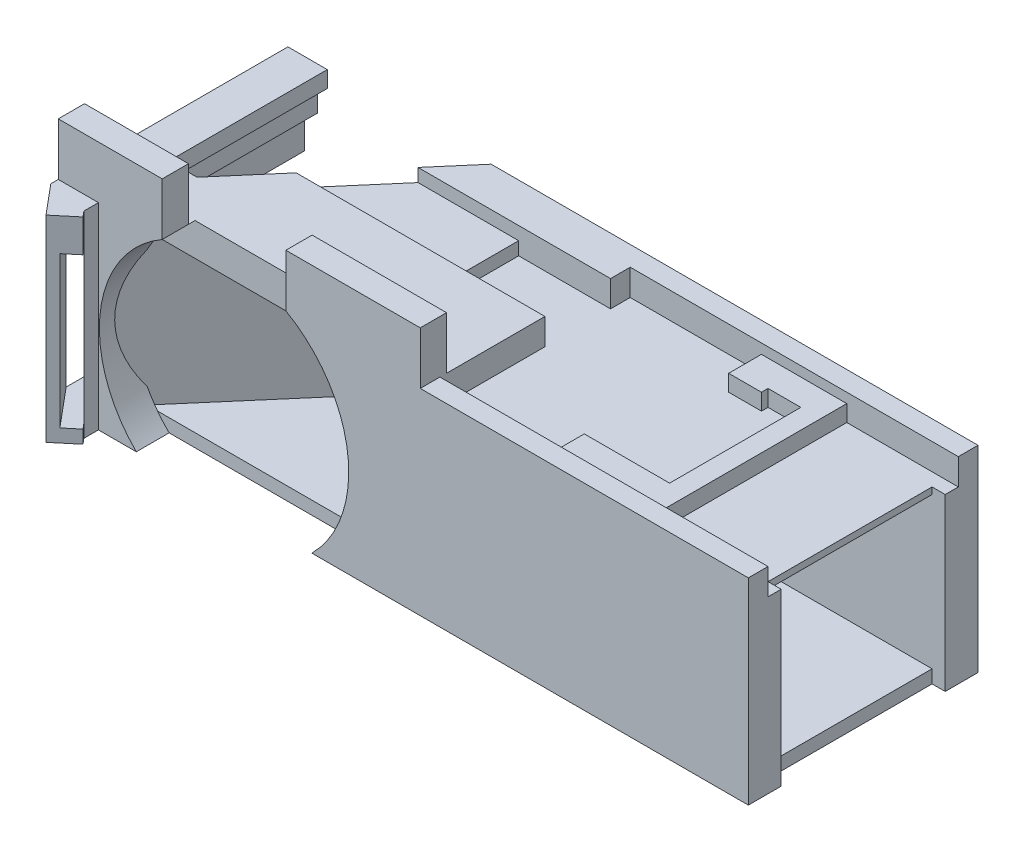
from build123d import *

# Parameters (mm, degrees)
BOSS_EXTRUDE3_DEPTH       = 30
SKETCH6_W                 = 25
SKETCH6_H                 = 23
CUT_EXTRUDE1_DEPTH        = 86
SKETCH7_W                 = 25
SKETCH7_H                 = 5
CUT_EXTRUDE2_DEPTH        = 7.5
SKETCH8_W                 = 25
SKETCH8_H                 = 2
CUT_EXTRUDE3_DEPTH        = 1
SKETCH9_R                 = 19
CUT_EXTRUDE4_DEPTH        = 5
BOSS_EXTRUDE4_DEPTH       = 30
SKETCH10_W                = 1.856561782
SKETCH10_H                = 30
BOSS_EXTRUDE5_DEPTH       = 3
BOSS_EXTRUDE6_DEPTH       = 30
SKETCH11_W                = 2.5
SKETCH11_H                = 23
CUT_EXTRUDE5_DEPTH        = 34.579503854
SKETCH12_W                = 29.135235428
SKETCH12_H                = 25
CUT_EXTRUDE6_DEPTH        = 3.5
SKETCH13_W                = 19.135235428
SKETCH13_H                = 5
CUT_EXTRUDE7_DEPTH        = 3.5
SKETCH14_W                = 29.135235428
SKETCH14_H                = 4
BOSS_EXTRUDE7_DEPTH       = 2
SKETCH16_W                = 29.135235428
SKETCH16_H                = 1.5
BOSS_EXTRUDE8_DEPTH       = 2
SKETCH17_W                = 2.551467674
SKETCH17_H                = 30
BOSS_EXTRUDE9_DEPTH       = 5
BOSS_EXTRUDE10_REACH      = 85.266
SKETCH18_W                = 29.135235428
SKETCH18_H                = 2.5
SKETCH19_W                = 2.48850009
SKETCH19_H                = 23
BOSS_EXTRUDE11_DEPTH      = 2
CUT_EXTRUDE8_START        = -2.4885
SKETCH20_W                = 2
SKETCH20_H                = 23
CUT_EXTRUDE8_DEPTH        = 21.736568
BOSS_EXTRUDE12_REACH      = 82.714
SKETCH21_W                = 2.023287715
SKETCH21_H                = 27.5
SKETCH22_W                = 35
SKETCH22_H                = 30
BOSS_EXTRUDE13_DEPTH      = 15.9
BOSS_EXTRUDE13_DEPTH_BACK = 7.5
SKETCH23_W                = 25
SKETCH23_H                = 23
CUT_EXTRUDE9_DEPTH        = 24.4
SKETCH24_W                = 25
SKETCH24_H                = 5
CUT_EXTRUDE10_DEPTH       = 2
SKETCH25_W                = 50
SKETCH25_H                = 29
CUT_EXTRUDE11_DEPTH       = 4
SKETCH26_W                = 3
SKETCH26_H                = 29
BOSS_EXTRUDE14_DEPTH      = 2.5
SKETCH27_W                = 5
SKETCH27_H                = 5
BOSS_EXTRUDE15_DEPTH      = 2.5
BOSS_EXTRUDE16_REACH      = 27
SKETCH28_W                = 4
SKETCH28_H                = 2.5
SKETCH29_W                = 13
SKETCH29_H                = 5
BOSS_EXTRUDE17_DEPTH      = 2.5
SKETCH30_W                = 10
SKETCH30_H                = 4
CUT_EXTRUDE12_DEPTH       = 14
CUT_EXTRUDE13_REACH       = 43.166
SKETCH31_W                = 10
SKETCH31_H                = 2
SKETCH32_W                = 2
SKETCH32_H                = 25
CUT_EXTRUDE14_DEPTH       = 27
SKETCH33_W                = 20.479278159
SKETCH33_H                = 4
BOSS_EXTRUDE18_DEPTH      = 8
SKETCH34_W                = 15.845031547
SKETCH34_H                = 4
BOSS_EXTRUDE19_DEPTH      = 8


with BuildPart() as part:
    # Sketch2 → Boss-Extrude3 (new body)
    with BuildSketch(Plane(origin=(0, 0, 0), x_dir=(1, 0, 0), z_dir=(0, 1, 0))):
        Polygon((-105.912162162, 13.018018018), (-20.912162162, 13.018018018), (-20.912162162, 48.018018018), (-75.912162162, 48.018018018), align=None)
    extrude(amount=BOSS_EXTRUDE3_DEPTH)

    # Sketch6 → Cut-Extrude1 (cut, through all)
    with BuildSketch(Plane(origin=(-20.912162162, 0, 0), x_dir=(0, 0, -1), z_dir=(1, 0, 0))):
        with Locations((30.518018018, 13.5)):
            Rectangle(SKETCH6_W, SKETCH6_H)
    extrude(amount=-CUT_EXTRUDE1_DEPTH, mode=Mode.SUBTRACT)

    # Sketch7 → Cut-Extrude2 (cut)
    with BuildSketch(Plane(origin=(-20.912162162, 0, 0), x_dir=(0, 0, -1), z_dir=(1, 0, 0))):
        with Locations((30.518018018, 27.5)):
            Rectangle(SKETCH7_W, SKETCH7_H)
    extrude(amount=-CUT_EXTRUDE2_DEPTH, mode=Mode.SUBTRACT)

    # Sketch8 → Cut-Extrude3 (cut)
    with BuildSketch(Plane(origin=(-20.912162162, 0, 0), x_dir=(0, 0, -1), z_dir=(1, 0, 0))):
        with Locations((30.518018018, 1)):
            Rectangle(SKETCH8_W, SKETCH8_H)
    extrude(amount=-CUT_EXTRUDE3_DEPTH, mode=Mode.SUBTRACT)

    # Sketch9 → Cut-Extrude4 (cut)
    with BuildSketch(Plane.XY.offset(-13.018018018)):
        with Locations((-84.912162162, 13.5)):
            Circle(SKETCH9_R)
    extrude(amount=-CUT_EXTRUDE4_DEPTH, mode=Mode.SUBTRACT)

    # Sketch3 → Boss-Extrude4 (add)
    with BuildSketch(Plane(origin=(0, 0, 0), x_dir=(1, 0, 0), z_dir=(0, 1, 0))):
        Polygon((-106.412808957, 7.383361614), (-110.17791555, 11.88278259), (-79.204856611, 48.018018018), (-75.912162162, 48.018018018), (-105.912162162, 13.018018018), (-103.345157358, 9.950366419), align=None)
    extrude(amount=BOSS_EXTRUDE4_DEPTH)

    # Sketch10 → Boss-Extrude5 (add)
    with BuildSketch(Plane.XY.offset(-13.018018018)):
        with Locations((-104.983881271, 15)):
            Rectangle(SKETCH10_W, SKETCH10_H)
    extrude(amount=BOSS_EXTRUDE5_DEPTH)

    # Sketch4 → Boss-Extrude6 (add)
    with BuildSketch(Plane(origin=(0, 0, 0), x_dir=(1, 0, 0), z_dir=(0, 1, 0))):
        Polygon((-110.17791555, 11.88278259), (-110.17791555, 48.018018018), (-104.17791555, 48.018018018), (-104.17791555, 18.88278259), align=None)
    extrude(amount=BOSS_EXTRUDE6_DEPTH)

    # Sketch11 → Cut-Extrude5 (cut, through all)
    with BuildSketch(Plane(origin=(-47.459390138, 0, -56.715466139), x_dir=(0.7669129, 0, -0.641751201), z_dir=(0.641751201, 0, 0.7669129))):
        with Locations((-74.121074711, 13.5)):
            Rectangle(SKETCH11_W, SKETCH11_H)
    extrude(amount=-CUT_EXTRUDE5_DEPTH, mode=Mode.SUBTRACT)

    # Sketch12 → Cut-Extrude6 (cut)
    with BuildSketch(Plane(origin=(-104.17791555, 0, 0), x_dir=(0, 0, -1), z_dir=(1, 0, 0))):
        with Locations((33.450400304, 15)):
            Rectangle(SKETCH12_W, SKETCH12_H)
    extrude(amount=-CUT_EXTRUDE6_DEPTH, mode=Mode.SUBTRACT)

    # Sketch13 → Cut-Extrude7 (cut, through all)
    with BuildSketch(Plane(origin=(-107.67791555, 0, 0), x_dir=(0, 0, -1), z_dir=(1, 0, 0))):
        with Locations((38.450400304, 15)):
            Rectangle(SKETCH13_W, SKETCH13_H)
    extrude(amount=-CUT_EXTRUDE7_DEPTH, mode=Mode.SUBTRACT)

    # Sketch14 → Boss-Extrude7 (add)
    with BuildSketch(Plane(origin=(-107.67791555, 0, 0), x_dir=(0, 0, -1), z_dir=(1, 0, 0))):
        with Locations((33.450400304, 25.5)):
            Rectangle(SKETCH14_W, SKETCH14_H)
    extrude(amount=BOSS_EXTRUDE7_DEPTH)

    # Sketch16 → Boss-Extrude8 (add)
    with BuildSketch(Plane(origin=(-107.67791555, 0, 0), x_dir=(0, 0, -1), z_dir=(1, 0, 0))):
        with Locations((33.450400304, 3.25)):
            Rectangle(SKETCH16_W, SKETCH16_H)
    extrude(amount=BOSS_EXTRUDE8_DEPTH)

    # Sketch17 → Boss-Extrude9 (add)
    with BuildSketch(Plane(origin=(0, 0, -18.88278259), x_dir=(-1, 0, 0), z_dir=(0, 0, -1))):
        with Locations((102.902181713, 15)):
            Rectangle(SKETCH17_W, SKETCH17_H)
    extrude(amount=BOSS_EXTRUDE9_DEPTH)

    # Boss-Extrude10: up to this face of the body (flat: up to its plane)
    boss_extrude10_end = Plane(part.part.faces().sort_by_distance((-90.415652244, 15, -34.938756447))[0])
    # Sketch18 → Boss-Extrude10 (add, up to the picked face)
    with BuildSketch(Plane(origin=(-104.17791555, 0, 0), x_dir=(0, 0, -1), z_dir=(1, 0, 0)), mode=Mode.PRIVATE) as boss_extrude10_sk1:
        with Locations((33.450400304, 1.25)):
            Rectangle(SKETCH18_W, SKETCH18_H)
    boss_extrude10_tool1 = split(extrude(boss_extrude10_sk1.sketch, amount=BOSS_EXTRUDE10_REACH, mode=Mode.PRIVATE), bisect_by=boss_extrude10_end, keep=Keep.BOTH, mode=Mode.PRIVATE)
    add(boss_extrude10_tool1.solids().sort_by_distance((-104.177916, 1.25, -33.4504))[0])

    # Sketch19 → Boss-Extrude11 (add)
    with BuildSketch(Plane(origin=(-67.487678855, 0, -57.846581876), x_dir=(0.650791373, 0, -0.759256602), z_dir=(0.759256602, 0, 0.650791373))):
        with Locations((-31.723015124, 13.5)):
            Rectangle(SKETCH19_W, SKETCH19_H)
    extrude(amount=BOSS_EXTRUDE11_DEPTH)

    # Sketch20 → Cut-Extrude8 (cut)
    with BuildSketch(Plane(origin=(-19.835317387, 0, 23.141203618), x_dir=(-0.759256602, 0, -0.650791373), z_dir=(0.650791373, 0, -0.759256602)).offset(CUT_EXTRUDE8_START)):
        with Locations((87.886522218, 13.5)):
            Rectangle(SKETCH20_W, SKETCH20_H)
    extrude(amount=CUT_EXTRUDE8_DEPTH, mode=Mode.SUBTRACT)

    # Boss-Extrude12: up to this face of the body (flat: up to its plane)
    boss_extrude12_end = Plane(part.part.faces().sort_by_distance((-90.415652244, 16.25, -34.938756447))[0])
    # Sketch21 → Boss-Extrude12 (add, up to the picked face)
    with BuildSketch(Plane(origin=(-101.626447876, 0, 0), x_dir=(0, 0, -1), z_dir=(1, 0, 0)), mode=Mode.PRIVATE) as boss_extrude12_sk1:
        with Locations((22.871138733, 16.25)):
            Rectangle(SKETCH21_W, SKETCH21_H)
    boss_extrude12_tool1 = split(extrude(boss_extrude12_sk1.sketch, amount=BOSS_EXTRUDE12_REACH, mode=Mode.PRIVATE), bisect_by=boss_extrude12_end, keep=Keep.BOTH, mode=Mode.PRIVATE)
    add(boss_extrude12_tool1.solids().sort_by_distance((-101.626448, 16.25, -22.871139))[0])

    # Sketch22 → Boss-Extrude13 (add, two sides)
    with BuildSketch(Plane(origin=(-20.912162162, 0, 0), x_dir=(0, 0, -1), z_dir=(1, 0, 0))) as boss_extrude13_sk:
        with Locations((30.518018018, 15)):
            Rectangle(SKETCH22_W, SKETCH22_H)
    extrude(amount=BOSS_EXTRUDE13_DEPTH)
    extrude(boss_extrude13_sk.sketch, amount=-BOSS_EXTRUDE13_DEPTH_BACK)

    # Sketch23 → Cut-Extrude9 (cut, through all)
    with BuildSketch(Plane.ZY.offset(28.412162162)):
        with Locations((-30.518018018, 13.5)):
            Rectangle(SKETCH23_W, SKETCH23_H)
    extrude(amount=-CUT_EXTRUDE9_DEPTH, mode=Mode.SUBTRACT)

    # Sketch24 → Cut-Extrude10 (cut)
    with BuildSketch(Plane(origin=(-5.012162162, 0, 0), x_dir=(0, 0, -1), z_dir=(1, 0, 0))):
        with Locations((30.518018018, 27.5)):
            Rectangle(SKETCH24_W, SKETCH24_H)
    extrude(amount=-CUT_EXTRUDE10_DEPTH, mode=Mode.SUBTRACT)

    # Sketch25 → Cut-Extrude11 (cut)
    with BuildSketch(Plane(origin=(0, 30, 0), x_dir=(1, 0, 0), z_dir=(0, 1, 0))):
        with Locations((-30.012162162, 30.518018018)):
            Rectangle(SKETCH25_W, SKETCH25_H)
    extrude(amount=-CUT_EXTRUDE11_DEPTH, mode=Mode.SUBTRACT)

    # Sketch26 → Boss-Extrude14 (add)
    with BuildSketch(Plane(origin=(0, 26, 0), x_dir=(1, 0, 0), z_dir=(0, 1, 0))):
        with Locations((-23.512162162, 30.518018018)):
            Rectangle(SKETCH26_W, SKETCH26_H)
    extrude(amount=BOSS_EXTRUDE14_DEPTH)

    # Sketch27 → Boss-Extrude15 (add)
    with BuildSketch(Plane(origin=(0, 26, 0), x_dir=(1, 0, 0), z_dir=(0, 1, 0))):
        with Locations((-32.512162162, 42.518018018)):
            Rectangle(SKETCH27_W, SKETCH27_H)
    extrude(amount=BOSS_EXTRUDE15_DEPTH)

    # Sketch28 → Boss-Extrude16 (add, up to next)
    with BuildSketch(Plane(origin=(-30.012162162, 0, 0), x_dir=(0, 0, -1), z_dir=(1, 0, 0)), mode=Mode.PRIVATE) as boss_extrude16_sk1:
        with Locations((43.018018018, 27.25)):
            Rectangle(SKETCH28_W, SKETCH28_H)
    boss_extrude16_tool1 = extrude(boss_extrude16_sk1.sketch, amount=BOSS_EXTRUDE16_REACH, mode=Mode.PRIVATE) - part.part
    add(boss_extrude16_tool1.solids().sort_by_distance((-30.012162, 27.25, -43.018018))[0])

    # Sketch29 → Boss-Extrude17 (add)
    with BuildSketch(Plane(origin=(0, 26, 0), x_dir=(1, 0, 0), z_dir=(0, 1, 0))):
        with Locations((-31.512162162, 18.518018018)):
            Rectangle(SKETCH29_W, SKETCH29_H)
    extrude(amount=BOSS_EXTRUDE17_DEPTH)

    # Sketch30 → Cut-Extrude12 (cut)
    with BuildSketch(Plane(origin=(-55.012162162, 0, 0), x_dir=(0, 0, -1), z_dir=(1, 0, 0))):
        with Locations((37.018018018, 28)):
            Rectangle(SKETCH30_W, SKETCH30_H)
    extrude(amount=-CUT_EXTRUDE12_DEPTH, mode=Mode.SUBTRACT)

    # Sketch31 → Cut-Extrude13 (cut, up to next)
    with BuildSketch(Plane(origin=(-69.012162162, 0, 0), x_dir=(0, 0, -1), z_dir=(1, 0, 0)), mode=Mode.PRIVATE) as cut_extrude13_sk1:
        with Locations((37.018018018, 29)):
            Rectangle(SKETCH31_W, SKETCH31_H)
    cut_extrude13_tool1 = extrude(cut_extrude13_sk1.sketch, amount=-CUT_EXTRUDE13_REACH, mode=Mode.PRIVATE) & part.part
    add(cut_extrude13_tool1.solids().sort_by_distance((-69.012162, 29, -37.018018))[0], mode=Mode.SUBTRACT)

    # Sketch32 → Cut-Extrude14 (cut, through all)
    with BuildSketch(Plane(origin=(0, 26, 0), x_dir=(1, 0, 0), z_dir=(0, 1, 0))):
        with Locations((-6.012162162, 30.518018018)):
            Rectangle(SKETCH32_W, SKETCH32_H)
    extrude(amount=-CUT_EXTRUDE14_DEPTH, mode=Mode.SUBTRACT)

    # Sketch33 → Boss-Extrude18 (add)
    with BuildSketch(Plane(origin=(0, 30, 0), x_dir=(1, 0, 0), z_dir=(0, 1, 0))):
        with Locations((-65.251801242, 15.018018018)):
            Rectangle(SKETCH33_W, SKETCH33_H)
    extrude(amount=BOSS_EXTRUDE18_DEPTH)

    # Sketch34 → Boss-Extrude19 (add)
    with BuildSketch(Plane(origin=(0, 30, 0), x_dir=(1, 0, 0), z_dir=(0, 1, 0))):
        with Locations((-102.255399777, 15.018018018)):
            Rectangle(SKETCH34_W, SKETCH34_H)
    extrude(amount=BOSS_EXTRUDE19_DEPTH)


solid = part.part
